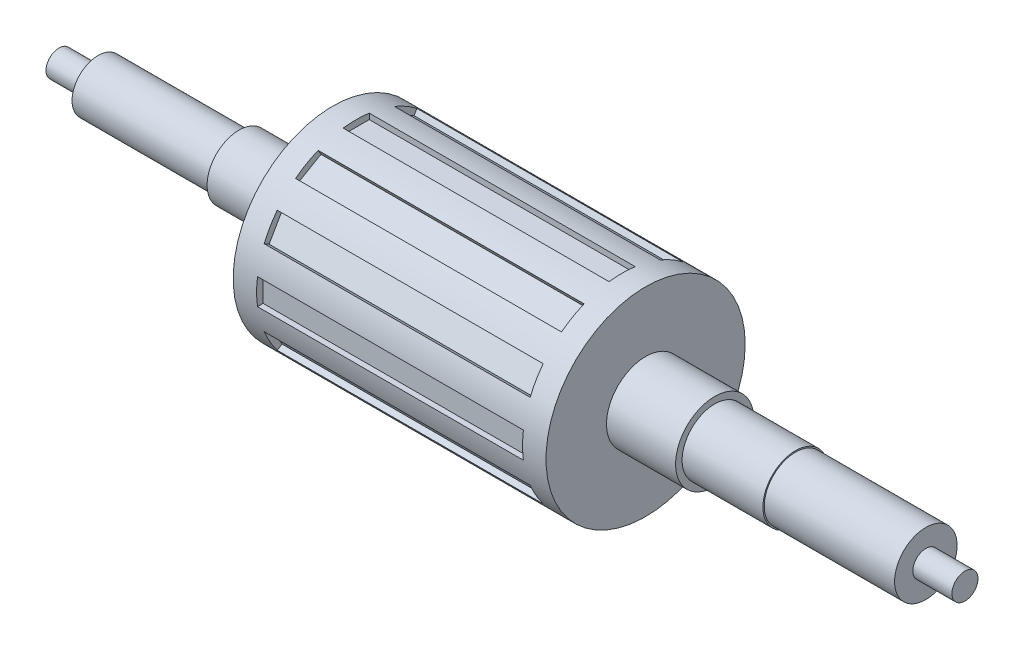
from build123d import *

# Parameters (mm, degrees)
CUT_EXTRUDE2_DEPTH = 102
CIRPATTERN2_COUNT  = 12


with BuildPart() as part:
    # Sketch1 → Revolve1 (revolve)
    with BuildSketch(Plane.XY, mode=Mode.PRIVATE) as revolve1_sk:
        Polygon((0, 0), (0, 5), (15, 5), (15, 10), (69, 10), (69, 12.2), (105, 12.2), (105, 38.2), (225, 38.2), (225, 15), (251.5, 15), (251.5, 12.5), (282.5, 12.5), (282.5, 12), (332.5, 12), (332.5, 5), (347.5, 5), (347.5, 0), align=None)
    revolve(revolve1_sk.sketch.rotate(Axis((347.5, 0, 0), (-1, 0, 0)), 90), axis=Axis((347.5, 0, 0), (-1, 0, 0)))  # turned: the seam where the file's is

    # Sketch2 → Cut-Extrude2 (cut)
    with BuildSketch(Plane(origin=(216, 0, 0), x_dir=(0, 0, -1), z_dir=(1, 0, 0))):
        Polygon((38.2, 0), (38.2, 5), (35.7, 5), (35.7, -5), (38.2, -5), align=None)
    cut_extrude2 = extrude(amount=-CUT_EXTRUDE2_DEPTH, mode=Mode.SUBTRACT)

    # CirPattern2: Cut-Extrude2 ×12 about axis
    cirpattern2_axis = Axis((0, 0, 0), (1, 0, 0))
    for i in range(1, CIRPATTERN2_COUNT):
        add(cut_extrude2.rotate(cirpattern2_axis, i * 360 / CIRPATTERN2_COUNT), mode=Mode.SUBTRACT)


solid = part.part
